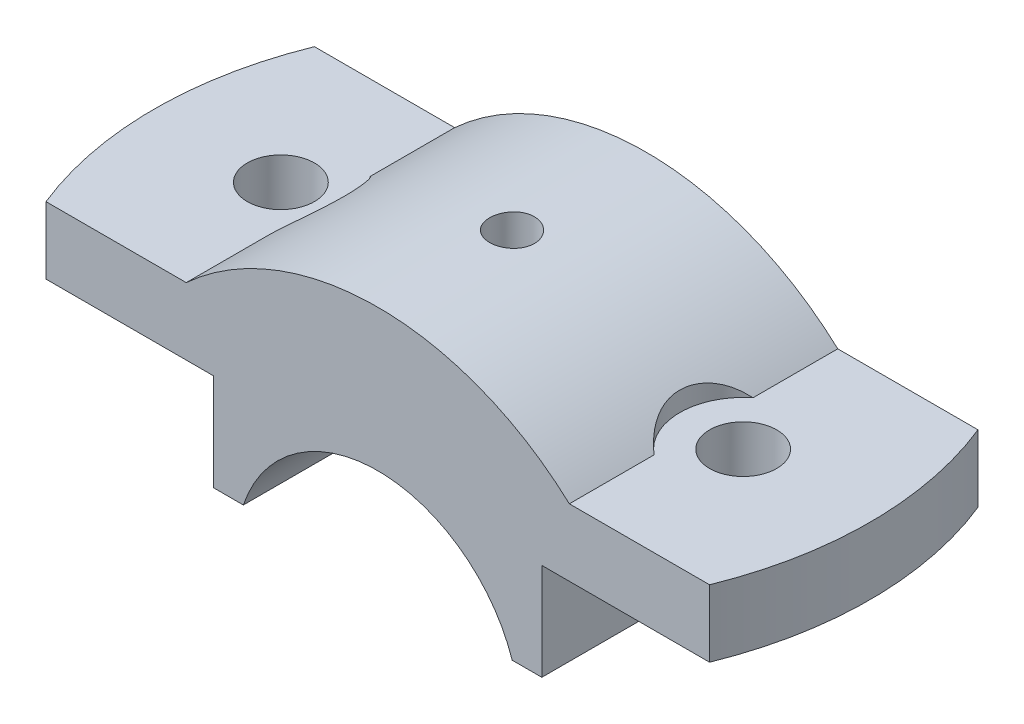
from build123d import *

# Parameters (mm, degrees)
BOSS_EXTRUDE1_DEPTH = 18
SKETCH2_R           = 4.5
CUT_EXTRUDE1_DEPTH  = 23
SKETCH4_R           = 8.5
CUT_EXTRUDE2_DEPTH  = 11
CUT_EXTRUDE3_DEPTH  = 23
SKETCH6_R           = 8.5
CUT_EXTRUDE4_DEPTH  = 11.0000001


with BuildPart() as part:
    # Sketch1 → Boss-Extrude1 (new body, symmetric)
    with BuildSketch(Plane.XY):
        with BuildLine():
            Line((-22, 6), (-18.027756377, 6))
            ThreePointArc((-18.027756377, 6), (0, 19), (18.027756377, 6))
            Line((18.027756377, 6), (22, 6))
            Line((22, 6), (22, 19))
            Line((22, 19), (50, 19))
            Line((50, 19), (50, 28))
            Line((50, 28), (25.690465157, 28))
            ThreePointArc((25.690465157, 28), (0, 38), (-25.690465157, 28))
            Line((-25.690465157, 28), (-50, 28))
            Line((-50, 28), (-50, 19))
            Line((-50, 19), (-22, 19))
            Line((-22, 19), (-22, 6))
        make_face()
    extrude(amount=BOSS_EXTRUDE1_DEPTH, both=True)

    # Sketch2 → Cut-Extrude1 (cut, through all)
    with BuildSketch(Plane(origin=(0, 28, 0), x_dir=(1, 0, 0), z_dir=(0, 1, 0))):
        with Locations(Location((-31, 0, 0), (0, 0, 270))):  # turned: the seam where the file's is
            Circle(SKETCH2_R)
        with Locations(Location((31, 0, 0), (0, 0, 270))):  # turned: the seam where the file's is
            Circle(SKETCH2_R)
    extrude(amount=-CUT_EXTRUDE1_DEPTH, mode=Mode.SUBTRACT)

    # Sketch4 → Cut-Extrude2 (cut, through all)
    with BuildSketch(Plane(origin=(0, 28, 0), x_dir=(1, 0, 0), z_dir=(0, 1, 0))):
        with Locations((-31, 0)):
            Circle(SKETCH4_R)
    extrude(amount=CUT_EXTRUDE2_DEPTH, mode=Mode.SUBTRACT)

    # Sketch5 → Cut-Extrude3 (cut, through all)
    with BuildSketch(Plane(origin=(0, 28, 0), x_dir=(1, 0, 0), z_dir=(0, 1, 0))):
        with BuildLine():
            Line((-44.497190923, 18), (-50, 18))
            Line((-50, 18), (-50, -18))
            Line((-50, -18), (-44.497190923, -18))
            ThreePointArc((-44.497190923, -18), (-48, 0), (-44.497190923, 18))
        make_face()
        with BuildLine():
            Line((50, 18), (44.497190923, 18))
            ThreePointArc((44.497190923, 18), (48, 0), (44.497190923, -18))
            Line((44.497190923, -18), (50, -18))
            Line((50, -18), (50, 18))
        make_face()
    extrude(amount=-CUT_EXTRUDE3_DEPTH, mode=Mode.SUBTRACT)

    # Sketch6 → Cut-Extrude4 (cut, through all)
    with BuildSketch(Plane(origin=(0, 28, 0), x_dir=(1, 0, 0), z_dir=(0, 1, 0))):
        with Locations((31, 0)):
            Circle(SKETCH6_R)
    extrude(amount=CUT_EXTRUDE4_DEPTH, mode=Mode.SUBTRACT)

    # Sketch8 → CBORE for M5 Hex Head Bolt1 (revolve, cut)
    with BuildSketch(Plane(origin=(0, 38, 0), x_dir=(0, 0, 1), z_dir=(1, 0, 0))):
        Polygon((0, 0), (0, 32), (2.5, 32), (2.5, 13.495), (2.995, 13), (3, 13), (3, 0), align=None)
    revolve(axis=Axis((0, 44.35, 0), (0, -1, 0)), mode=Mode.SUBTRACT)


solid = part.part
